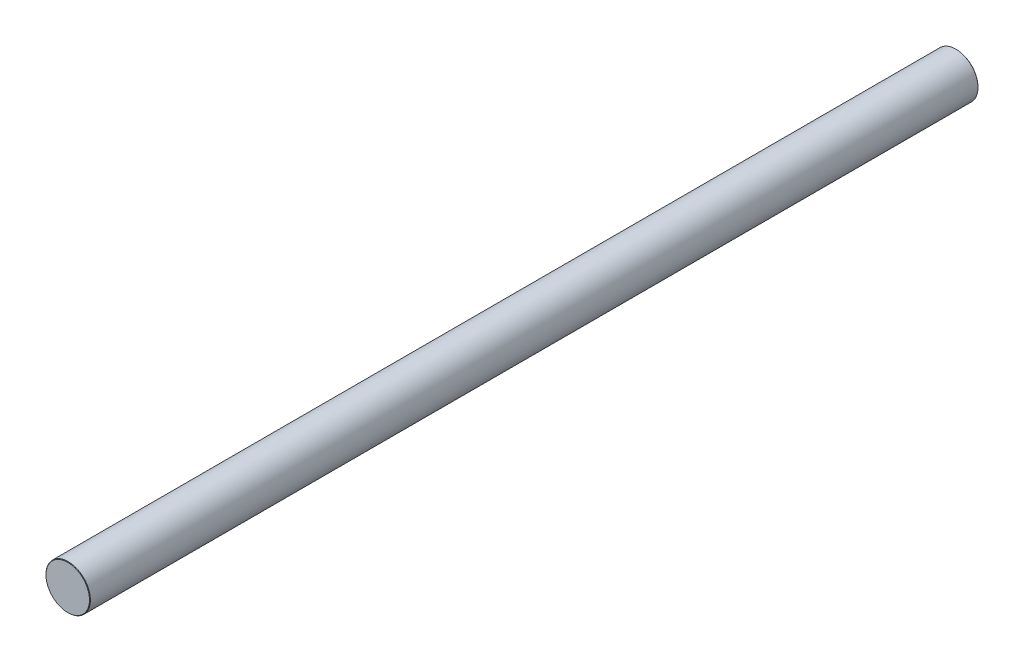
from build123d import *

# Parameters (mm, degrees)
SKETCH_1_R      = 5
EXTRUDE_1_DEPTH = 200
CHAMFER_1_SIZE  = 0.1


with BuildPart() as part:
    # Эскиз1 → Бобышка-Вытянуть1 (new body)
    with BuildSketch(Plane.XY):
        Circle(SKETCH_1_R)
    extrude(amount=EXTRUDE_1_DEPTH)

    # Фаска1
    chamfer_1_edges = [part.edges().sort_by_distance(p)[0] for p in [
        (-5, 0, 0),
        (-5, 0, 200),
    ]]
    chamfer(chamfer_1_edges, length=CHAMFER_1_SIZE)


solid = part.part
